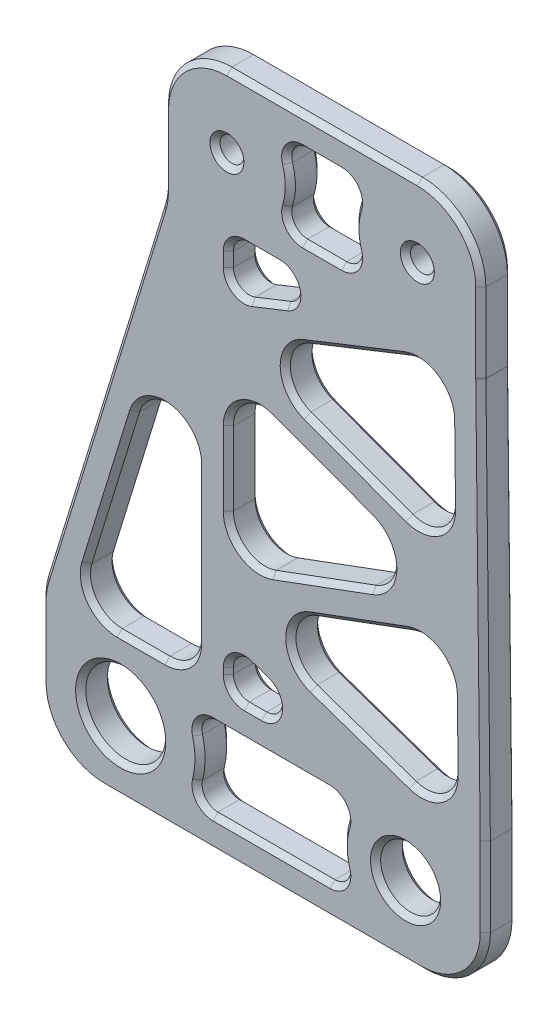
from build123d import *

# Parameters (mm, degrees)
SKETCH1_R           = 4
SKETCH1_R_2         = 3
SKETCH1_R_3         = 1.190625
BOSS_EXTRUDE1_DEPTH = 1.5875
FILLET1_R           = 6.35
FILLET3_R           = 3.175
FILLET2_R           = 1.5875
CHAMFER1_SIZE       = 0.508


with BuildPart() as part:
    # Sketch1 → Boss-Extrude1 (new body, symmetric)
    with BuildSketch(Plane.XY):
        Polygon((15.875, 0), (-15.875, 0), (-15.875, -14.2875), (-28.12542, -54.12486), (-28.12542, -68.41236), (16.32458, -68.41236), (16.32458, -54.12486), (15.875, -14.2875), align=None)
        with Locations((-20.14982, -61.26861)):
            Circle(SKETCH1_R, mode=Mode.SUBTRACT)
        Polygon((-12.553271791, -54.12486), (-24.803691791, -54.12486), (-12.553271791, -14.2875), align=None, mode=Mode.SUBTRACT)
        with BuildLine():
            ThreePointArc((-13.275743357, -65.23736), (-12.21232, -61.26861), (-13.275743357, -57.29986))
            Line((-13.275743357, -57.29986), (3.392012839, -57.29986))
            ThreePointArc((3.392012839, -57.29986), (1.99898, -61.26861), (3.392012839, -65.23736))
            Line((3.392012839, -65.23736), (-13.275743357, -65.23736))
        make_face(mode=Mode.SUBTRACT)
        Polygon((-9.378271791, -49.708144558), (3.418196766, -54.12486), (-9.378271791, -54.12486), align=None, mode=Mode.SUBTRACT)
        with Locations((8.34898, -61.26861)):
            Circle(SKETCH1_R_2, mode=Mode.SUBTRACT)
        Polygon((12.968365445, -38.067407542), (13.14958, -54.12486), (-9.378271791, -46.349346745), align=None, mode=Mode.SUBTRACT)
        Polygon((-9.378271791, -42.963311587), (-9.378271791, -26.427639416), (12.930311889, -34.695475502), align=None, mode=Mode.SUBTRACT)
        with Locations((-9.525, -7.14375)):
            Circle(SKETCH1_R_3, mode=Mode.SUBTRACT)
        Polygon((-9.378271791, -23.041604258), (12.7, -14.2875), (12.891938678, -31.295218759), align=None, mode=Mode.SUBTRACT)
        Polygon((-9.378271791, -19.626132417), (-9.378271791, -14.2875), (4.086015818, -14.2875), align=None, mode=Mode.SUBTRACT)
        with BuildLine():
            ThreePointArc((-4.568032839, -11.1125), (-3.175, -7.14375), (-4.568032839, -3.175))
            Line((-4.568032839, -3.175), (4.568032839, -3.175))
            ThreePointArc((4.568032839, -3.175), (3.175, -7.14375), (4.568032839, -11.1125))
            Line((4.568032839, -11.1125), (-4.568032839, -11.1125))
        make_face(mode=Mode.SUBTRACT)
        with Locations((9.525, -7.14375)):
            Circle(SKETCH1_R_3, mode=Mode.SUBTRACT)
    extrude(amount=BOSS_EXTRUDE1_DEPTH, both=True)

    # Fillet1
    fillet1_edges = [part.edges().sort_by_distance(p)[0] for p in [
        (-15.875, 0, 0),
        (15.875, 0, 0),
        (15.875, -14.2875, 0),
        (16.32458, -68.41236, 0),
        (-28.12542, -68.41236, 0),
        (-28.12542, -54.12486, 0),
        (-15.875, -14.2875, 0),
    ]]
    fillet(fillet1_edges, radius=FILLET1_R)

    # Fillet3
    fillet3_edges = [part.edges().sort_by_distance(p)[0] for p in [
        (-24.803691791, -54.12486, 0),
        (-12.553271791, -54.12486, 0),
        (-12.553271791, -14.2875, 0),
        (-9.378271791, -46.349346745, 0),
        (13.14958, -54.12486, 0),
        (12.968365445, -38.067407542, 0),
        (12.891938678, -31.295218759, 0),
        (12.7, -14.2875, 0),
        (-9.378271791, -23.041604258, 0),
        (-9.378271791, -42.963311587, 0),
        (12.930311889, -34.695475502, 0),
        (-9.378271791, -26.427639416, 0),
    ]]
    fillet(fillet3_edges, radius=FILLET3_R)

    # Fillet2
    fillet2_edges = [part.edges().sort_by_distance(p)[0] for p in [
        (-13.275743357, -57.29986, 0),
        (-13.275743357, -65.23736, 0),
        (3.392012839, -65.23736, 0),
        (3.392012839, -57.29986, 0),
        (-9.378271791, -49.708144558, 0),
        (-9.378271791, -54.12486, 0),
        (3.418196766, -54.12486, 0),
        (-9.378271791, -14.2875, 0),
        (-9.378271791, -19.626132417, 0),
        (4.086015818, -14.2875, 0),
        (-4.568032839, -3.175, 0),
        (-4.568032839, -11.1125, 0),
        (4.568032839, -11.1125, 0),
        (4.568032839, -3.175, 0),
    ]]
    fillet(fillet2_edges, radius=FILLET2_R)

    # Chamfer1
    chamfer1_edges = [part.edges().sort_by_distance(p)[0] for p in [
        (-15.875, -9.841601911, -1.5875),
        (-15.875, -9.841601911, 1.5875),
        (0, 0, -1.5875),
        (15.875, -10.31875, -1.5875),
        (16.32458, -58.09361, -1.5875),
        (-5.90042, -68.41236, -1.5875),
        (-28.12542, -58.570758089, -1.5875),
        (-22.00021, -34.20618, -1.5875),
        (-28.054905028, -54.135457192, -1.5875),
        (-26.265548061, -66.552488061, -1.5875),
        (14.464708061, -66.552488061, -1.5875),
        (14.015128061, -1.859871939, -1.5875),
        (-14.015128061, -1.859871939, -1.5875),
        (0, 0, 1.5875),
        (-22.00021, -34.20618, 1.5875),
        (-28.12542, -58.570758089, 1.5875),
        (-5.90042, -68.41236, 1.5875),
        (16.32458, -58.09361, 1.5875),
        (15.875, -10.31875, 1.5875),
        (-28.054905028, -54.135457192, 1.5875),
        (-26.265548061, -66.552488061, 1.5875),
        (14.464708061, -66.552488061, 1.5875),
        (14.015128061, -1.859871939, 1.5875),
        (-14.015128061, -1.859871939, 1.5875),
        (16.09979, -34.20618, -1.5875),
        (16.09979, -34.20618, 1.5875),
        (-15.945514972, -14.276902808, -1.5875),
        (-15.945514972, -14.276902808, 1.5875),
        (-0.10128663, -29.865804464, -1.5875),
        (-0.10128663, -29.865804464, 1.5875),
        (-9.378271791, -34.695475502, -1.5875),
        (-9.378271791, -34.695475502, 1.5875),
        (-0.10128663, -39.525146539, -1.5875),
        (-0.10128663, -39.525146539, 1.5875),
        (-21.151697335, -42.248873882, -1.5875),
        (-21.151697335, -42.248873882, 1.5875),
        (-18.116944229, -54.12486, -1.5875),
        (-18.116944229, -54.12486, 1.5875),
        (16.09979, -34.20618, 1.5875),
        (-12.553271791, -43.182093356, -1.5875),
        (-12.553271791, -43.182093356, 1.5875),
        (3.841364052, -41.449986757, -1.5875),
        (3.841364052, -41.449986757, 1.5875),
        (3.948565436, -50.949119527, -1.5875),
        (3.948565436, -50.949119527, 1.5875),
        (13.058972722, -46.096133771, -1.5875),
        (13.058972722, -46.096133771, 1.5875),
        (3.473191475, -27.804514951, -1.5875),
        (3.473191475, -27.804514951, 1.5875),
        (12.795969339, -22.79135938, -1.5875),
        (12.795969339, -22.79135938, 1.5875),
        (3.362429483, -17.989876101, -1.5875),
        (3.362429483, -17.989876101, 1.5875),
        (-8.016758506, -28.384243052, -1.5875),
        (-8.016758506, -28.384243052, 1.5875),
        (6.968985543, -34.695475502, -1.5875),
        (6.968985543, -34.695475502, 1.5875),
        (-8.016758506, -41.006707951, -1.5875),
        (-8.016758506, -41.006707951, 1.5875),
        (-23.059397867, -52.836345246, -1.5875),
        (-23.059397867, -52.836345246, 1.5875),
        (-13.48320776, -53.19492403, -1.5875),
        (-13.48320776, -53.19492403, 1.5875),
        (-15.256422297, -32.274584198, -1.5875),
        (-15.256422297, -32.274584198, 1.5875),
        (-3.129798547, -46.27883031, -1.5875),
        (-3.129798547, -46.27883031, 1.5875),
        (11.781247601, -52.227774089, -1.5875),
        (11.781247601, -52.227774089, 1.5875),
        (11.643194785, -39.994890676, -1.5875),
        (11.643194785, -39.994890676, 1.5875),
        (11.49318993, -29.309102149, -1.5875),
        (11.49318993, -29.309102149, 1.5875),
        (11.346429974, -16.304677591, -1.5875),
        (11.346429974, -16.304677591, 1.5875),
        (-3.686729116, -22.977373, -1.5875),
        (-3.686729116, -22.977373, 1.5875),
        (-6.400906525, -50.735785511, -1.5875),
        (-6.400906525, -50.735785511, 1.5875),
        (-9.378271791, -52.236415433, -1.5875),
        (-9.378271791, -52.236415433, 1.5875),
        (-6.918850622, -54.12486, -1.5875),
        (-6.918850622, -54.12486, 1.5875),
        (-6.007749691, -14.2875, -1.5875),
        (-6.007749691, -14.2875, 1.5875),
        (-9.378271791, -16.581973875, -1.5875),
        (-9.378271791, -16.581973875, 1.5875),
        (-5.422618305, -18.057703359, -1.5875),
        (-5.422618305, -18.057703359, 1.5875),
        (-5.075095409, -65.23736, -1.5875),
        (-5.075095409, -65.23736, 1.5875),
        (1.99898, -61.26861, -1.5875),
        (1.99898, -61.26861, 1.5875),
        (-5.075095409, -57.29986, -1.5875),
        (-5.075095409, -57.29986, 1.5875),
        (-12.21232, -61.26861, -1.5875),
        (-12.21232, -61.26861, 1.5875),
        (0, -11.1125, -1.5875),
        (0, -11.1125, 1.5875),
        (3.175, -7.14375, -1.5875),
        (3.175, -7.14375, 1.5875),
        (0, -3.175, -1.5875),
        (0, -3.175, 1.5875),
        (-3.175, -7.14375, -1.5875),
        (-3.175, -7.14375, 1.5875),
        (-8.712162044, -50.642723307, -1.5875),
        (-8.712162044, -50.642723307, 1.5875),
        (-8.913303806, -53.659892015, -1.5875),
        (-8.913303806, -53.659892015, 1.5875),
        (-4.481297592, -52.79994927, -1.5875),
        (-4.481297592, -52.79994927, 1.5875),
        (-8.913303806, -14.752467985, -1.5875),
        (-8.913303806, -14.752467985, 1.5875),
        (-8.682752781, -18.602159904, -1.5875),
        (-8.682752781, -18.602159904, 1.5875),
        (-2.665420565, -15.577144588, -1.5875),
        (-2.665420565, -15.577144588, 1.5875),
        (2.056971006, -64.589037666, -1.5875),
        (2.056971006, -64.589037666, 1.5875),
        (2.056971006, -57.948182334, -1.5875),
        (2.056971006, -57.948182334, 1.5875),
        (-12.182307353, -64.622001242, -1.5875),
        (-12.182307353, -64.622001242, 1.5875),
        (-12.182307353, -57.915218758, -1.5875),
        (-12.182307353, -57.915218758, 1.5875),
        (3.232991006, -10.464177666, -1.5875),
        (3.232991006, -10.464177666, 1.5875),
        (3.232991006, -3.823322334, -1.5875),
        (3.232991006, -3.823322334, 1.5875),
        (-3.232991006, -10.464177666, -1.5875),
        (-3.232991006, -10.464177666, 1.5875),
        (-3.232991006, -3.823322334, -1.5875),
        (-3.232991006, -3.823322334, 1.5875),
        (-24.14982, -61.26861, -1.5875),
        (-24.14982, -61.26861, 1.5875),
        (5.34898, -61.26861, -1.5875),
        (5.34898, -61.26861, 1.5875),
        (-10.715625, -7.14375, -1.5875),
        (-10.715625, -7.14375, 1.5875),
        (8.334375, -7.14375, -1.5875),
        (8.334375, -7.14375, 1.5875),
        (16.09979, -34.20618, -1.5875),
    ]]
    chamfer(chamfer1_edges, length=CHAMFER1_SIZE)


solid = part.part
